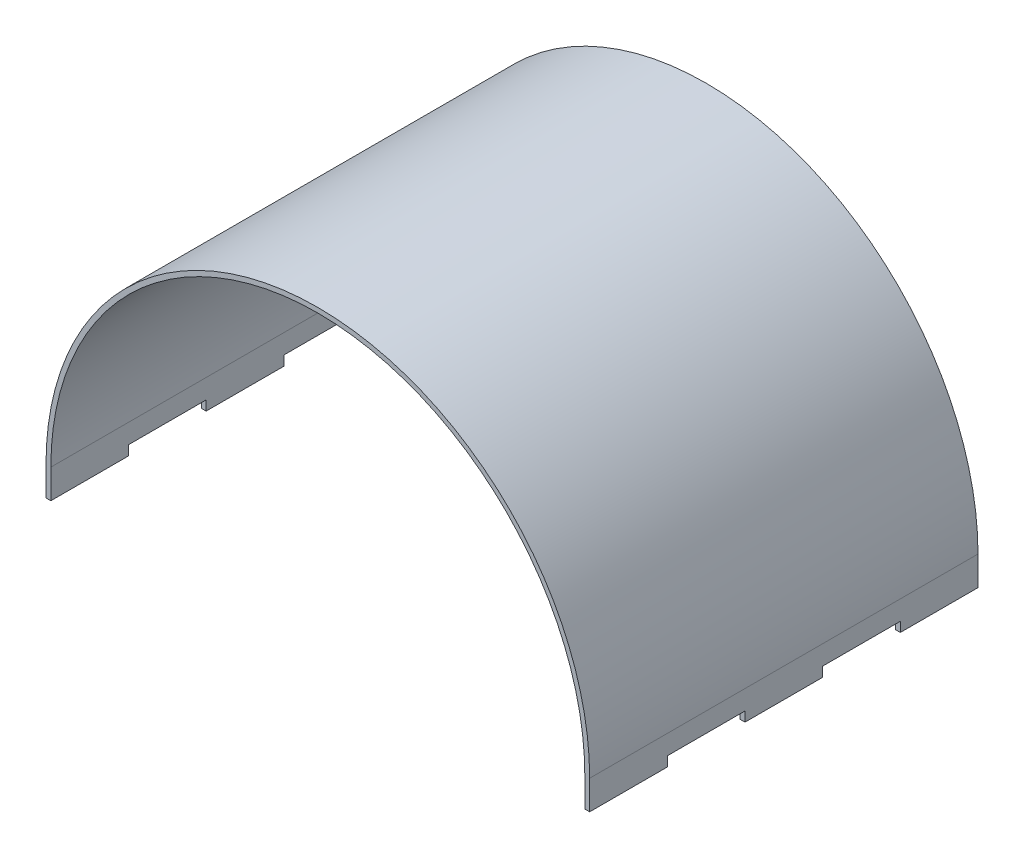
from build123d import *

# Parameters (mm, degrees)
BOSS_EXTRUDE1_DEPTH = 254
SKETCH2_W           = 50.8
SKETCH2_H           = 6.35
CUT_EXTRUDE1_DEPTH  = 356.6


with BuildPart() as part:
    # Sketch1 → Boss-Extrude1 (new body)
    with BuildSketch(Plane.XY):
        with BuildLine():
            Line((0, 0), (3.175, 0))
            Line((3.175, 0), (3.175, 19.05))
            ThreePointArc((3.175, 19.05), (177.8, 193.675), (352.425, 19.05))
            Line((352.425, 19.05), (352.425, 0))
            Line((352.425, 0), (355.6, 0))
            Line((355.6, 0), (355.6, 19.05))
            ThreePointArc((355.6, 19.05), (177.8, 196.85), (0, 19.05))
            Line((0, 19.05), (0, 0))
        make_face()
    extrude(amount=BOSS_EXTRUDE1_DEPTH)

    # Sketch2 → Cut-Extrude1 (cut, through all)
    with BuildSketch(Plane(origin=(355.6, 0, 0), x_dir=(0, 0, -1), z_dir=(1, 0, 0))):
        with Locations((-177.8, 3.175)):
            Rectangle(SKETCH2_W, SKETCH2_H)
        with Locations((-76.2, 3.175)):
            Rectangle(SKETCH2_W, SKETCH2_H)
    extrude(amount=-CUT_EXTRUDE1_DEPTH, mode=Mode.SUBTRACT)


solid = part.part
